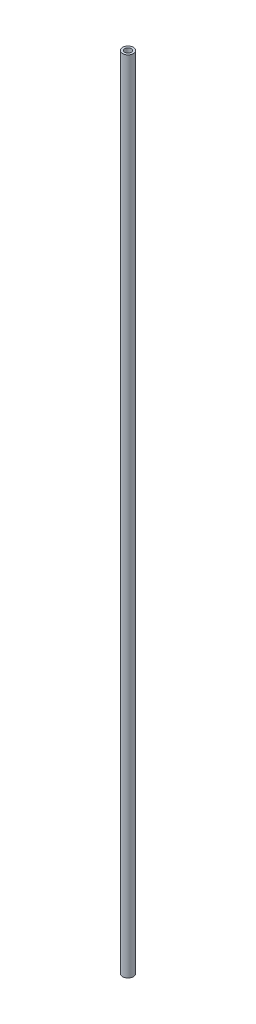
from build123d import *

# Parameters (mm, degrees)
SKETCH1_R           = 6.223
SKETCH1_R_2         = 3.683
BOSS_EXTRUDE1_DEPTH = 457.2


with BuildPart() as part:
    # Sketch1 → Boss-Extrude1 (new body, symmetric)
    with BuildSketch(Plane(origin=(0, 0, 0), x_dir=(1, 0, 0), z_dir=(0, 1, 0))):
        Circle(SKETCH1_R)
        Circle(SKETCH1_R_2, mode=Mode.SUBTRACT)
    extrude(amount=BOSS_EXTRUDE1_DEPTH, both=True)


solid = part.part
